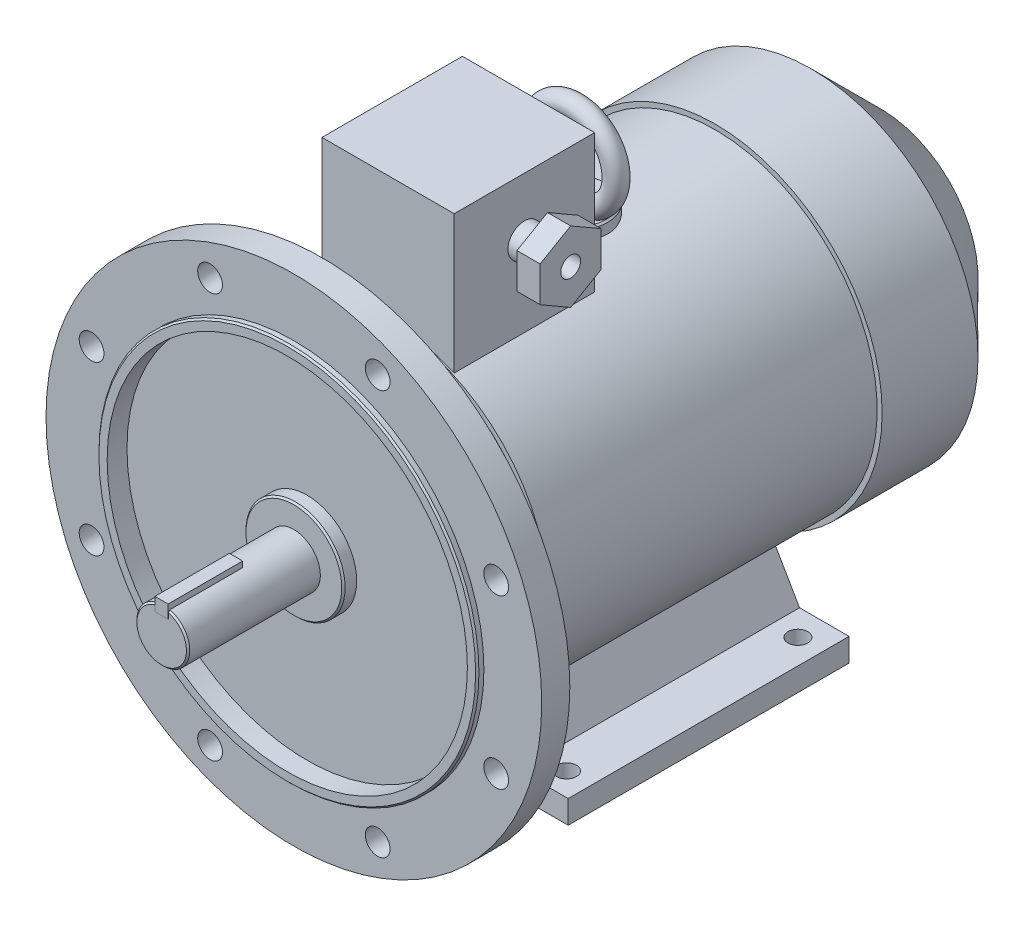
from build123d import *

# Parameters (mm, degrees)
SKETCH_1_R           = 16
EXTRUDE_1_DEPTH      = 80
SKETCH_2_R           = 150
EXTRUDE_2_DEPTH      = 17
SKETCH_3_W           = 8
SKETCH_3_H           = 8
EXTRUDE_3_DEPTH      = 0.1
EXTRUDE_3_DEPTH_BACK = 45
SKETCH_4_R           = 115
SKETCH_4_R_2         = 109
EXTRUDE_4_DEPTH      = 4
SKETCH_5_R           = 109
SKETCH_5_R_2         = 30
CUT_EXTRUDE_1_DEPTH  = 8
CHAMFER_1_SIZE       = 1
SKETCH_6_R           = 7.5
CUT_EXTRUDE_2_DEPTH  = 18
SKETCH_7_R           = 95
EXTRUDE_5_DEPTH      = 39
SKETCH_8_R           = 98
EXTRUDE_6_DEPTH      = 199
SKETCH_9_R           = 101
EXTRUDE_7_DEPTH      = 100
CHAMFER_2_SIZE       = 42
EXTRUDE_8_DEPTH      = 170
CUT_EXTRUDE_3_REACH  = 264
SKETCH_11_R          = 6
SKETCH_12_W          = 80
SKETCH_12_H          = 85
EXTRUDE_9_DEPTH      = 173
SKETCH_13_R          = 20
EXTRUDE_10_DEPTH     = 103
CHAMFER_3_SIZE       = 1
SKETCH_15_R          = 6
SKETCH_16_R          = 10
EXTRUDE_11_DEPTH     = 14
EXTRUDE_12_DEPTH     = 14
SKETCH_18_R          = 6
CUT_EXTRUDE_4_DEPTH  = 14


with BuildPart() as part:
    # Эскиз1 → Вытянуть1 (new body)
    with BuildSketch(Plane.XY):
        Circle(SKETCH_1_R)
    extrude(amount=EXTRUDE_1_DEPTH)

    # Эскиз2 → Вытянуть2 (add)
    with BuildSketch(Plane(origin=(0, 0, 0), x_dir=(-1, 0, 0), z_dir=(0, 0, -1))):
        Circle(SKETCH_2_R)
    extrude(amount=EXTRUDE_2_DEPTH)

    # Эскиз3 → Вытянуть3 (add, two sides)
    with BuildSketch(Plane.XY.offset(80)) as extrude_3_sk:
        with Locations((0, 15)):
            Rectangle(SKETCH_3_W, SKETCH_3_H)
    extrude(amount=EXTRUDE_3_DEPTH)
    extrude(extrude_3_sk.sketch, amount=-EXTRUDE_3_DEPTH_BACK)

    # Эскиз4 → Вытянуть4 (add)
    with BuildSketch(Plane.XY):
        with Locations(Location((0, 0, 0), (0, 0, 180))):  # turned: the seam where the file's is
            Circle(SKETCH_4_R)
        Circle(SKETCH_4_R_2, mode=Mode.SUBTRACT)
    extrude(amount=EXTRUDE_4_DEPTH)

    # Эскиз5 → Вырез-Вытянуть1 (cut)
    with BuildSketch(Plane.XY):
        Circle(SKETCH_5_R)
        Circle(SKETCH_5_R_2, mode=Mode.SUBTRACT)
    extrude(amount=-CUT_EXTRUDE_1_DEPTH, mode=Mode.SUBTRACT)

    # Фаска1
    chamfer_1_edges = [part.edges().sort_by_distance(p)[0] for p in [
        (115, 0, 4),
        (-30, 0, 0),
        (-9.797958971, -12.649110641, 80),
    ]]
    chamfer(chamfer_1_edges, length=CHAMFER_1_SIZE)

    # Эскиз6 → Вырез-Вытянуть2 (cut, through all)
    with BuildSketch(Plane.XY):
        with Locations((-50.705554788, 122.414038058)):
            Circle(SKETCH_6_R)
        with Locations((50.705554788, 122.414038058)):
            Circle(SKETCH_6_R)
        with Locations((122.414038058, 50.705554788)):
            Circle(SKETCH_6_R)
        with Locations((122.414038058, -50.705554788)):
            Circle(SKETCH_6_R)
        with Locations((50.705554788, -122.414038058)):
            Circle(SKETCH_6_R)
        with Locations((-50.705554788, -122.414038058)):
            Circle(SKETCH_6_R)
        with Locations((-122.414038058, -50.705554788)):
            Circle(SKETCH_6_R)
        with Locations((-122.414038058, 50.705554788)):
            Circle(SKETCH_6_R)
    extrude(amount=-CUT_EXTRUDE_2_DEPTH, mode=Mode.SUBTRACT)

    # Эскиз7 → Вытянуть5 (add)
    with BuildSketch(Plane(origin=(0, 0, -17), x_dir=(-1, 0, 0), z_dir=(0, 0, -1))):
        Circle(SKETCH_7_R)
    extrude(amount=EXTRUDE_5_DEPTH)

    # Эскиз8 → Вытянуть6 (add)
    with BuildSketch(Plane(origin=(0, 0, -56), x_dir=(-1, 0, 0), z_dir=(0, 0, -1))):
        Circle(SKETCH_8_R)
    extrude(amount=EXTRUDE_6_DEPTH)

    # Эскиз9 → Вытянуть7 (add)
    with BuildSketch(Plane(origin=(0, 0, -255), x_dir=(-1, 0, 0), z_dir=(0, 0, -1))):
        Circle(SKETCH_9_R)
    extrude(amount=EXTRUDE_7_DEPTH)

    # Фаска2
    chamfer_2_edges = [part.edges().sort_by_distance(p)[0] for p in [
        (101, 0, -355),
    ]]
    chamfer(chamfer_2_edges, length=CHAMFER_2_SIZE)

    # Эскиз10 → Вытянуть8 (add)
    with BuildSketch(Plane.XY.offset(-56)):
        Polygon((-110, -112), (-71.917096231, -112), (-51.440399562, -76.533320997), (-63.564755215, -69.533320997), (-80, -98), (-110, -98), align=None)
        Polygon((110, -98), (110, -112), (71.917096231, -112), (51.440399562, -76.533320997), (63.564755215, -69.533320997), (80, -98), align=None)
    extrude(amount=-EXTRUDE_8_DEPTH)

    # Эскиз11 → Вырез-Вытянуть3 (cut, up to next)
    with BuildSketch(Plane.XZ.offset(112), mode=Mode.PRIVATE) as cut_extrude_3_sk1:
        with Locations(Location((95, -70, 0), (0, 0, 270))):  # turned: the seam where the file's is
            Circle(SKETCH_11_R)
    cut_extrude_3_tool1 = extrude(cut_extrude_3_sk1.sketch, amount=-CUT_EXTRUDE_3_REACH, mode=Mode.PRIVATE) & part.part
    add(cut_extrude_3_tool1.solids().sort_by_distance((95, -112, -70))[0], mode=Mode.SUBTRACT)
    # Эскиз11 → Вырез-Вытянуть3 (cut, up to next)
    with BuildSketch(Plane.XZ.offset(112), mode=Mode.PRIVATE) as cut_extrude_3_sk2:
        with Locations(Location((-95, -70, 0), (0, 0, 270))):  # turned: the seam where the file's is
            Circle(SKETCH_11_R)
    cut_extrude_3_tool2 = extrude(cut_extrude_3_sk2.sketch, amount=-CUT_EXTRUDE_3_REACH, mode=Mode.PRIVATE) & part.part
    add(cut_extrude_3_tool2.solids().sort_by_distance((-95, -112, -70))[0], mode=Mode.SUBTRACT)
    # Эскиз11 → Вырез-Вытянуть3 (cut, up to next)
    with BuildSketch(Plane.XZ.offset(112), mode=Mode.PRIVATE) as cut_extrude_3_sk3:
        with Locations(Location((95, -210, 0), (0, 0, 270))):  # turned: the seam where the file's is
            Circle(SKETCH_11_R)
    cut_extrude_3_tool3 = extrude(cut_extrude_3_sk3.sketch, amount=-CUT_EXTRUDE_3_REACH, mode=Mode.PRIVATE) & part.part
    add(cut_extrude_3_tool3.solids().sort_by_distance((95, -112, -210))[0], mode=Mode.SUBTRACT)
    # Эскиз11 → Вырез-Вытянуть3 (cut, up to next)
    with BuildSketch(Plane.XZ.offset(112), mode=Mode.PRIVATE) as cut_extrude_3_sk4:
        with Locations(Location((-95, -210, 0), (0, 0, 270))):  # turned: the seam where the file's is
            Circle(SKETCH_11_R)
    cut_extrude_3_tool4 = extrude(cut_extrude_3_sk4.sketch, amount=-CUT_EXTRUDE_3_REACH, mode=Mode.PRIVATE) & part.part
    add(cut_extrude_3_tool4.solids().sort_by_distance((-95, -112, -210))[0], mode=Mode.SUBTRACT)

    # Эскиз12 → Вытянуть9 (add)
    with BuildSketch(Plane(origin=(0, 0, 0), x_dir=(1, 0, 0), z_dir=(0, 1, 0))):
        with Locations((0, 99.5)):
            Rectangle(SKETCH_12_W, SKETCH_12_H)
    extrude(amount=EXTRUDE_9_DEPTH)

    # Эскиз13 → Вытянуть10 (add)
    with BuildSketch(Plane(origin=(0, 0, 0), x_dir=(1, 0, 0), z_dir=(0, 1, 0))):
        with Locations(Location((0, 170, 0), (0, 0, 90))):  # turned: the seam where the file's is
            Circle(SKETCH_13_R)
    extrude(amount=EXTRUDE_10_DEPTH)

    # Фаска3
    chamfer_3_edges = [part.edges().sort_by_distance(p)[0] for p in [
        (0, 103, -150),
    ]]
    chamfer(chamfer_3_edges, length=CHAMFER_3_SIZE)

    # По траектории1: sweep along a path in Эскиз14
    with BuildLine(Plane.XY.offset(-170)) as sweep_1_path:
        CenterArc((0, 128), 25, 0, 360)
    # Эскиз15 → По траектории1 (sweep)
    with BuildSketch(Plane(origin=(0, 0, 0), x_dir=(0, 0, -1), z_dir=(1, 0, 0))):
        with Locations((170, 153)):
            Circle(SKETCH_15_R)
    sweep(path=sweep_1_path.line)

    # Эскиз16 → Вытянуть11 (add)
    with BuildSketch(Plane(origin=(40, 0, 0), x_dir=(0, 0, -1), z_dir=(1, 0, 0))):
        with Locations(Location((99.5, 138, 0), (0, 0, 180))):  # turned: the seam where the file's is
            Circle(SKETCH_16_R)
    extrude(amount=EXTRUDE_11_DEPTH)

    # Эскиз17 → Вытянуть12 (add)
    with BuildSketch(Plane(origin=(54, 0, 0), x_dir=(0, 0, -1), z_dir=(1, 0, 0))):
        Polygon((99.5, 159.36195996), (81, 148.68097998), (81, 127.31902002), (99.5, 116.63804004), (118, 127.31902002), (118, 148.68097998), align=None)
    extrude(amount=EXTRUDE_12_DEPTH)

    # Эскиз18 → Вырез-Вытянуть4 (cut)
    with BuildSketch(Plane(origin=(68, 0, 0), x_dir=(0, 0, -1), z_dir=(1, 0, 0))):
        with Locations((99.5, 138)):
            Circle(SKETCH_18_R)
    extrude(amount=-CUT_EXTRUDE_4_DEPTH, mode=Mode.SUBTRACT)


solid = part.part
